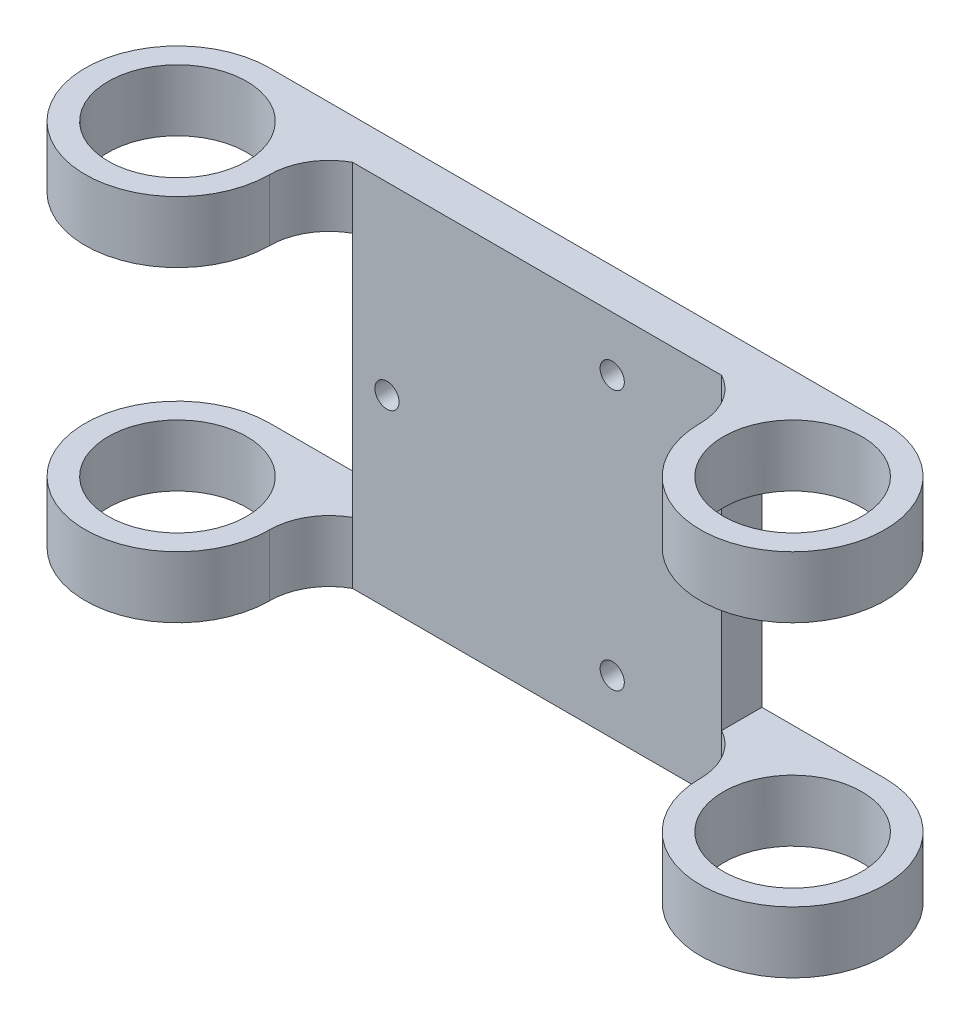
from build123d import *

# Parameters (mm, degrees)
SKETCH1_R               = 14.2875
BOSS_EXTRUDE1_DEPTH     = 76.2
SKETCH2_W               = 25.4
SKETCH2_H               = 50.8
SKETCH2_W_2             = 104.590829903
SKETCH2_W_3             = 68.699540571
SKETCH2_R               = 2.5
CUT_EXTRUDE1_DEPTH      = 1
CUT_EXTRUDE1_DEPTH_BACK = 39.1


with BuildPart() as part:
    # Sketch1 → Boss-Extrude1 (new body)
    with BuildSketch(Plane(origin=(0, 0, 0), x_dir=(1, 0, 0), z_dir=(0, 1, 0))):
        with BuildLine():
            Line((63.5, 0), (-63.5, 0))
            ThreePointArc((-63.5, 0), (-76.970384182, -32.520384182), (-44.45, -19.05))
            ThreePointArc((-44.45, -19.05), (-42.743933719, -12.807304268), (-38.1, -8.3))
            Line((-38.1, -8.3), (38.1, -8.3))
            ThreePointArc((38.1, -8.3), (42.743933719, -12.807304268), (44.45, -19.05))
            ThreePointArc((44.45, -19.05), (76.970384182, -32.520384182), (63.5, 0))
        make_face()
        with Locations((-63.5, -19.05)):
            Circle(SKETCH1_R, mode=Mode.SUBTRACT)
        with Locations((63.5, -19.05)):
            Circle(SKETCH1_R, mode=Mode.SUBTRACT)
    extrude(amount=BOSS_EXTRUDE1_DEPTH)

    # Sketch2 → Cut-Extrude1 (cut, two sides)
    with BuildSketch(Plane(origin=(0, 0, 0), x_dir=(-1, 0, 0), z_dir=(0, 0, -1))) as cut_extrude1_sk:
        with Locations((-50.8, 38.1)):
            Rectangle(SKETCH2_W, SKETCH2_H)
        with Locations((-115.795414952, 38.1)):
            Rectangle(SKETCH2_W_2, SKETCH2_H)
        with Locations((50.8, 38.1)):
            Rectangle(SKETCH2_W, SKETCH2_H)
        with Locations((97.849770285, 38.1)):
            Rectangle(SKETCH2_W_3, SKETCH2_H)
        with Locations((-15.500122677, 64.947)):
            Circle(SKETCH2_R)
        with Locations((-15.500122677, 11.253)):
            Circle(SKETCH2_R)
        with Locations((31.000245354, 38.1)):
            Circle(SKETCH2_R)
    extrude(amount=CUT_EXTRUDE1_DEPTH, mode=Mode.SUBTRACT)
    extrude(cut_extrude1_sk.sketch, amount=-CUT_EXTRUDE1_DEPTH_BACK, mode=Mode.SUBTRACT)


solid = part.part
